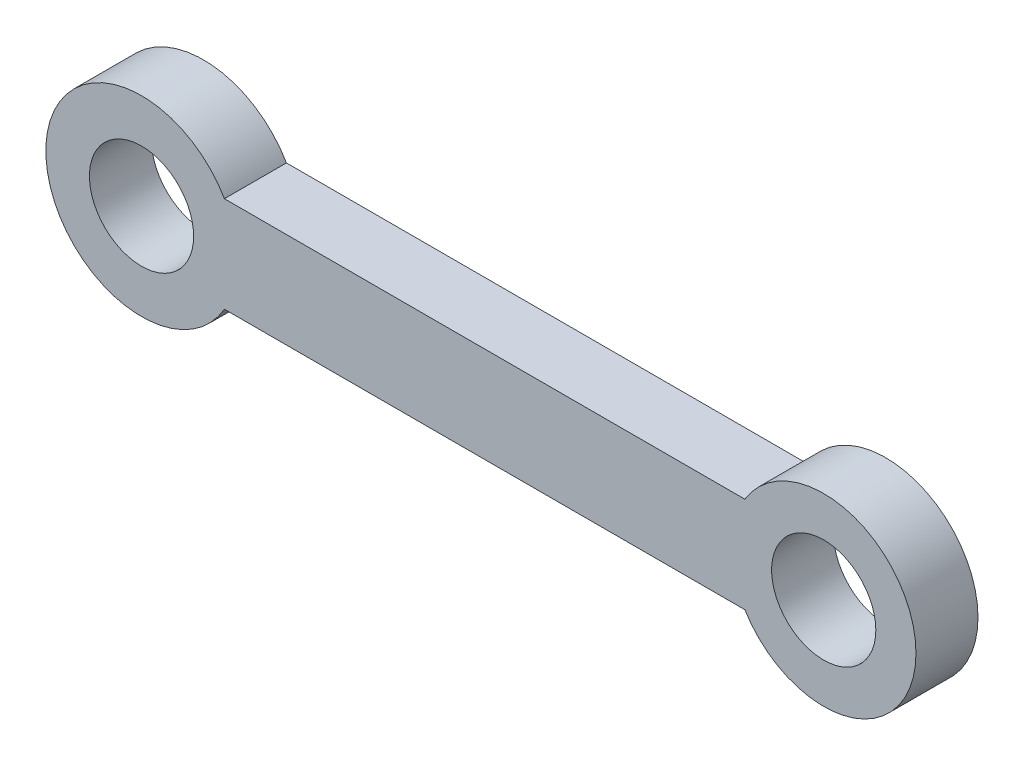
from build123d import *

# Parameters (mm, degrees)
SKETCH1_R           = 4.2
BOSS_EXTRUDE1_DEPTH = 5


with BuildPart() as part:
    # Sketch1 → Boss-Extrude1 (new body)
    with BuildSketch(Plane.XY):
        with BuildLine():
            Line((-20.817837651, 3.857948231), (21.141062747, 3.857948231))
            ThreePointArc((21.141062747, 3.857948231), (34.937731343, 0), (21.141062747, -3.857948231))
            Line((21.141062747, -3.857948231), (-20.817837651, -3.857948231))
            ThreePointArc((-20.817837651, -3.857948231), (-35.215896462, 0), (-20.817837651, 3.857948231))
        make_face()
        with Locations((-27.5, 0)):
            Circle(SKETCH1_R, mode=Mode.SUBTRACT)
        with Locations((27.5, 0)):
            Circle(SKETCH1_R, mode=Mode.SUBTRACT)
    extrude(amount=BOSS_EXTRUDE1_DEPTH)


solid = part.part
